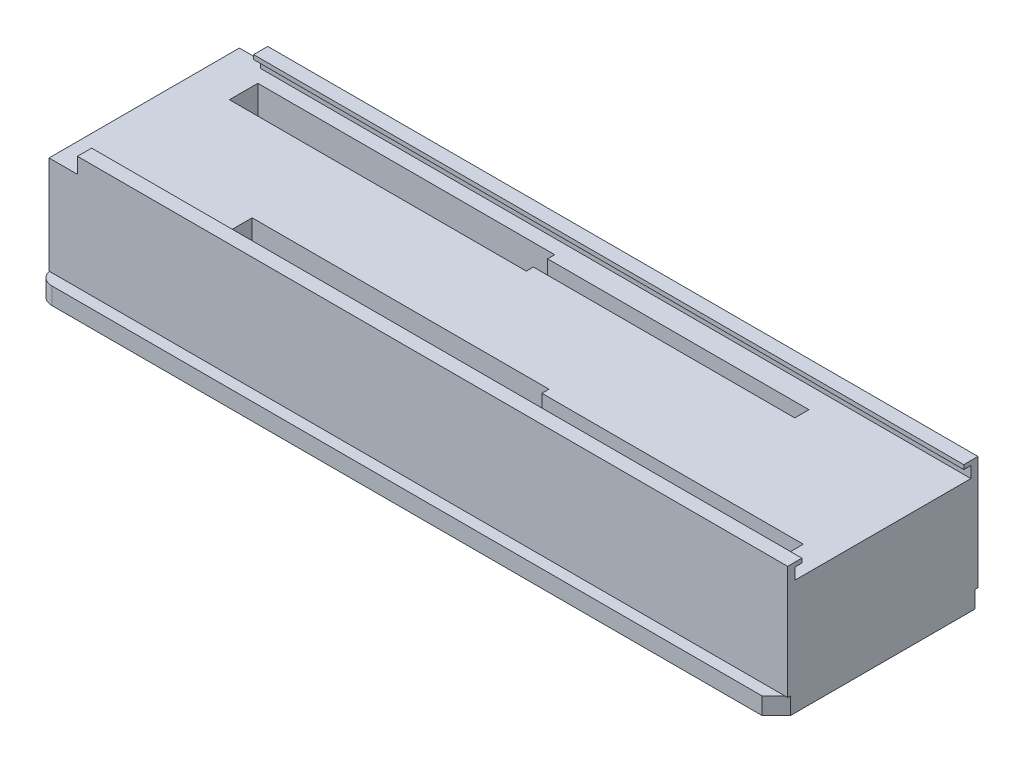
from build123d import *

# Parameters (mm, degrees)
SKETCH1_W           = 260
SKETCH1_H           = 75
BOSS_EXTRUDE1_DEPTH = 6
CHAMFER1_SIZE       = 5
FILLET1_R           = 5
SKETCH2_W           = 260
SKETCH2_H           = 67
BOSS_EXTRUDE2_DEPTH = 40
CUT_EXTRUDE1_DEPTH  = 261
SKETCH4_W           = 10
SKETCH4_H           = 67
CUT_EXTRUDE3_DEPTH  = 5.5
CUT_EXTRUDE4_DEPTH  = 35
SKETCH6_R           = 2.5
CUT_EXTRUDE5_DEPTH  = 6.5
SKETCH7_R           = 3
CUT_EXTRUDE6_DEPTH  = 5


with BuildPart() as part:
    # Sketch1 → Boss-Extrude1 (new body)
    with BuildSketch(Plane(origin=(0, 0, 0), x_dir=(1, 0, 0), z_dir=(0, 1, 0))):
        with Locations((130, 37.5)):
            Rectangle(SKETCH1_W, SKETCH1_H)
    extrude(amount=BOSS_EXTRUDE1_DEPTH)

    # Chamfer1
    chamfer1_edges = [part.edges().sort_by_distance(p)[0] for p in [
        (260, 3, -75),
        (260, 3, 0),
    ]]
    chamfer(chamfer1_edges, length=CHAMFER1_SIZE)

    # Fillet1
    fillet1_edges = [part.edges().sort_by_distance(p)[0] for p in [
        (0, 3, -75),
        (0, 3, 0),
    ]]
    fillet(fillet1_edges, radius=FILLET1_R)

    # Sketch2 → Boss-Extrude2 (add)
    with BuildSketch(Plane(origin=(0, 6, 0), x_dir=(1, 0, 0), z_dir=(0, 1, 0))):
        with Locations((130, 37.5)):
            Rectangle(SKETCH2_W, SKETCH2_H)
    extrude(amount=BOSS_EXTRUDE2_DEPTH)

    # Sketch3 → Cut-Extrude1 (cut, through all)
    with BuildSketch(Plane.ZY):
        Polygon((-66, 46), (-66, 44.5), (-68.5, 44.5), (-68.5, 40.5), (-6.5, 40.5), (-6.5, 44.5), (-9, 44.5), (-9, 46), align=None)
    extrude(amount=-CUT_EXTRUDE1_DEPTH, mode=Mode.SUBTRACT)

    # Sketch4 → Cut-Extrude3 (cut)
    with BuildSketch(Plane(origin=(0, 46, 0), x_dir=(1, 0, 0), z_dir=(0, 1, 0))):
        with Locations((5, 37.5)):
            Rectangle(SKETCH4_W, SKETCH4_H)
    extrude(amount=-CUT_EXTRUDE3_DEPTH, mode=Mode.SUBTRACT)

    # Sketch5 → Cut-Extrude4 (cut)
    with BuildSketch(Plane(origin=(0, 40.5, 0), x_dir=(1, 0, 0), z_dir=(0, 1, 0))):
        Polygon((14, 63.5), (14, 53.5), (118.5, 53.5), (118.5, 56), (210.5, 56), (210.5, 61), (118.5, 61), (118.5, 63.5), align=None)
        Polygon((54, 21.5), (54, 11.5), (158.5, 11.5), (158.5, 14), (250.5, 14), (250.5, 19), (158.5, 19), (158.5, 21.5), align=None)
    extrude(amount=-CUT_EXTRUDE4_DEPTH, mode=Mode.SUBTRACT)

    # Sketch6 → Cut-Extrude5 (cut, through all)
    with BuildSketch(Plane(origin=(0, 5.5, 0), x_dir=(1, 0, 0), z_dir=(0, 1, 0))):
        with Locations((208, 58.5)):
            Circle(SKETCH6_R)
        with Locations((248, 16.5)):
            Circle(SKETCH6_R)
    extrude(amount=-CUT_EXTRUDE5_DEPTH, mode=Mode.SUBTRACT)

    # Sketch7 → Cut-Extrude6 (cut)
    with BuildSketch(Plane.XZ):
        with Locations((170, -37.5)):
            Circle(SKETCH7_R)
    extrude(amount=-CUT_EXTRUDE6_DEPTH, mode=Mode.SUBTRACT)


solid = part.part
